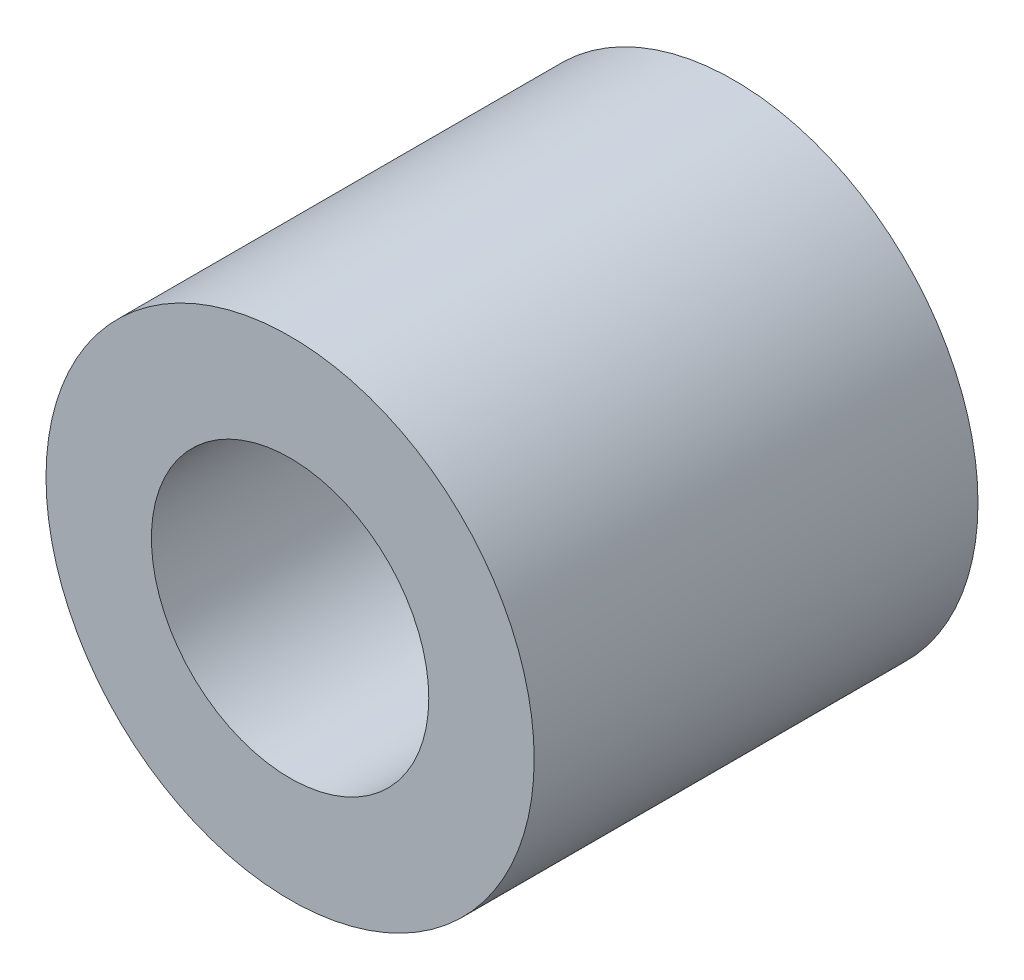
from build123d import *

# Parameters (mm, degrees)
SKETCH_1_R      = 2.2
SKETCH_1_R_2    = 1.25
EXTRUDE_2_DEPTH = 4


with BuildPart() as part:
    # 草图1 → 凸台-拉伸2 (new body)
    with BuildSketch(Plane.XY):
        Circle(SKETCH_1_R)
        Circle(SKETCH_1_R_2, mode=Mode.SUBTRACT)
    extrude(amount=EXTRUDE_2_DEPTH)


solid = part.part
